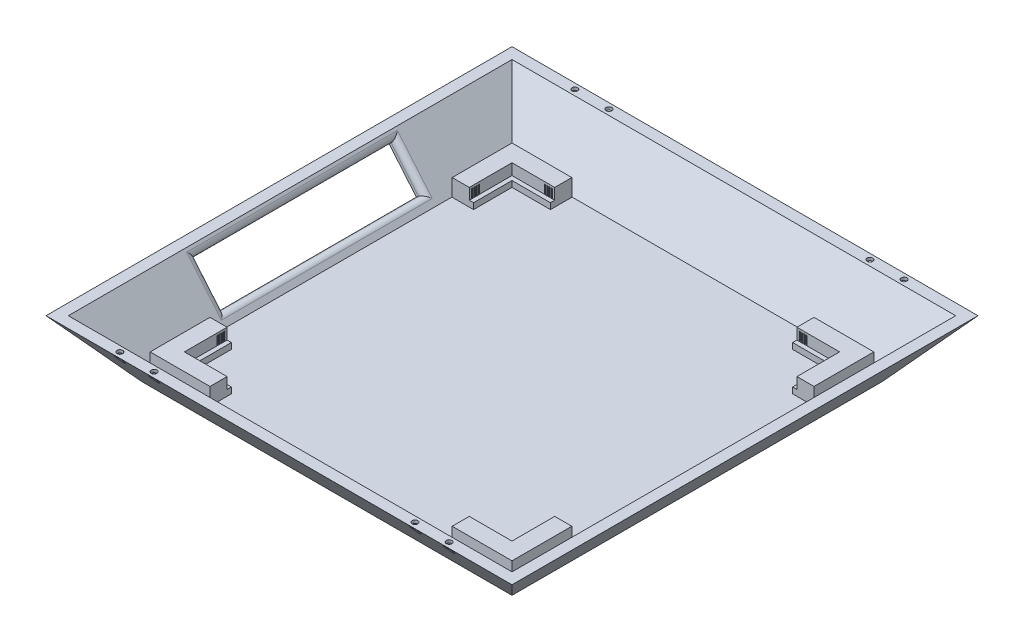
from build123d import *

# Parameters (mm, degrees)
SKETCH1_W            = 130
SKETCH1_H            = 130
BOSS_EXTRUDE1_DEPTH  = 20
BOSS_EXTRUDE1_DRAFT  = -40
SHELL1_T             = -3
BOSS_EXTRUDE2_DEPTH  = 6
BOSS_EXTRUDE3_DEPTH  = 2.1
SKETCH4_W            = 0.4
SKETCH4_H            = 3
BOSS_EXTRUDE4_DEPTH  = 0.2
CHAMFER2_SIZE        = 0.15
SKETCH5_W            = 0.4
SKETCH5_H            = 3
BOSS_EXTRUDE5_DEPTH  = 0.2
CHAMFER3_SIZE        = 0.15
SKETCH6_W            = 0.4
SKETCH6_H            = 3
BOSS_EXTRUDE6_DEPTH  = 0.2
CHAMFER4_SIZE        = 0.15
SKETCH7_W            = 0.4
SKETCH7_H            = 3
BOSS_EXTRUDE7_DEPTH  = 0.2
CHAMFER5_SIZE        = 0.15
SKETCH8_W            = 0.4
SKETCH8_H            = 3
BOSS_EXTRUDE8_DEPTH  = 0.2
CHAMFER6_SIZE        = 0.15
SKETCH9_W            = 0.4
SKETCH9_H            = 3
BOSS_EXTRUDE9_DEPTH  = 0.2
CHAMFER7_SIZE        = 0.15
SKETCH10_W           = 0.4
SKETCH10_H           = 3
BOSS_EXTRUDE10_DEPTH = 0.2
CHAMFER8_SIZE        = 0.15
SKETCH11_W           = 0.4
SKETCH11_H           = 3
BOSS_EXTRUDE11_DEPTH = 0.2
CHAMFER9_SIZE        = 0.15
SKETCH13_W           = 70
SKETCH13_H           = 15
CUT_EXTRUDE2_DEPTH   = 3.2
FILLET1_R            = 2
SKETCH22_R           = 1
CUT_EXTRUDE3_DEPTH   = 21.65
SKETCH22_5_R         = 1
CUT_EXTRUDE4_DEPTH   = 21.65
SKETCH22_6_R         = 1
CUT_EXTRUDE5_DEPTH   = 21.65
SKETCH22_7_R         = 1
CUT_EXTRUDE6_DEPTH   = 21.65
SKETCH22_8_R         = 1
CUT_EXTRUDE8_DEPTH   = 10
SKETCH22_9_R         = 1
CUT_EXTRUDE9_DEPTH   = 10
SKETCH22_10_R        = 1
CUT_EXTRUDE10_DEPTH  = 10
SKETCH22_11_R        = 1
CUT_EXTRUDE11_DEPTH  = 10
F_3DSKETCH3_R        = 1.5
CUT_EXTRUDE7_DEPTH   = 9
SKETCH23_R           = 1.5
CUT_EXTRUDE12_DEPTH  = 19


with BuildPart() as part:
    # Sketch1 → Boss-Extrude1 (with draft: the straight prism first)
    with BuildSketch(Plane(origin=(0, 0, 0), x_dir=(1, 0, 0), z_dir=(0, 1, 0))):
        Rectangle(SKETCH1_W, SKETCH1_H)
    extrude(amount=BOSS_EXTRUDE1_DEPTH)
    # Boss-Extrude1: the draft: its side faces are tilted about the plane it starts from
    boss_extrude1_sides = [part.faces().sort_by_distance(p)[0] for p in [
        (0, 10, 65),
        (65, 10, 0),
        (0, 10, -65),
        (-65, 10, 0),
    ]]
    draft(boss_extrude1_sides, Plane(origin=(0, 0, 0), x_dir=(1, 0, 0), z_dir=(0, 1, 0)), BOSS_EXTRUDE1_DRAFT)

    # Shell1
    shell1_openings = [part.faces().sort_by_distance(p)[0] for p in [
        (0, 20, 0),
    ]]
    offset(amount=SHELL1_T, openings=shell1_openings, kind=Kind.INTERSECTION)

    # Sketch2 → Boss-Extrude2 (add)
    with BuildSketch(Plane(origin=(0, 3, 0), x_dir=(1, 0, 0), z_dir=(0, 1, 0))):
        Polygon((-63.5, -63.5), (-42.5, -63.5), (-42.5, -57.5), (-57.5, -57.5), (-57.5, -42.5), (-63.5, -42.5), align=None)
        Polygon((57.5, -57.5), (42.5, -57.5), (42.5, -63.5), (63.5, -63.5), (63.5, -42.5), (57.5, -42.5), align=None)
        Polygon((-63.5, 42.5), (-57.5, 42.5), (-57.5, 57.5), (-42.5, 57.5), (-42.5, 63.5), (-63.5, 63.5), align=None)
        Polygon((57.5, 57.5), (57.5, 42.5), (63.5, 42.5), (63.5, 63.5), (42.5, 63.5), (42.5, 57.5), align=None)
    extrude(amount=BOSS_EXTRUDE2_DEPTH)

    # Sketch3 → Boss-Extrude3 (add)
    with BuildSketch(Plane(origin=(0, 3, 0), x_dir=(1, 0, 0), z_dir=(0, 1, 0))):
        Polygon((-57.5, -42.5), (-57.5, -57.5), (-42.5, -57.5), (-42.5, -56), (-56, -56), (-56, -42.5), align=None)
        Polygon((-57.5, 57.5), (-57.5, 42.5), (-56, 42.5), (-56, 56), (-42.5, 56), (-42.5, 57.5), align=None)
        Polygon((42.5, -56), (42.5, -57.5), (57.5, -57.5), (57.5, -42.5), (56, -42.5), (56, -56), align=None)
        Polygon((42.5, 57.5), (42.5, 56), (56, 56), (56, 42.5), (57.5, 42.5), (57.5, 57.5), align=None)
    extrude(amount=BOSS_EXTRUDE3_DEPTH)

    # Sketch4 → Boss-Extrude4 (add)
    with BuildSketch(Plane.XY.offset(-57.5)):
        with Locations((-43.5, 6.75)):
            Rectangle(SKETCH4_W, SKETCH4_H)
        with Locations((-44.3, 6.75)):
            Rectangle(SKETCH4_W, SKETCH4_H)
        with Locations((-45.1, 6.75)):
            Rectangle(SKETCH4_W, SKETCH4_H)
        with Locations((-45.9, 6.75)):
            Rectangle(SKETCH4_W, SKETCH4_H)
    extrude(amount=BOSS_EXTRUDE4_DEPTH)

    # Chamfer2
    chamfer2_edges = [part.edges().sort_by_distance(p)[0] for p in [
        (-43.3, 6.75, -57.3),
        (-43.7, 6.75, -57.3),
        (-44.1, 6.75, -57.3),
        (-44.5, 6.75, -57.3),
        (-44.9, 6.75, -57.3),
        (-45.3, 6.75, -57.3),
        (-45.7, 6.75, -57.3),
        (-46.1, 6.75, -57.3),
    ]]
    chamfer(chamfer2_edges, length=CHAMFER2_SIZE)

    # Sketch5 → Boss-Extrude5 (add)
    with BuildSketch(Plane(origin=(-57.5, 0, 0), x_dir=(0, 0, -1), z_dir=(1, 0, 0))):
        with Locations((43.5, 6.75)):
            Rectangle(SKETCH5_W, SKETCH5_H)
        with Locations((44.3, 6.75)):
            Rectangle(SKETCH5_W, SKETCH5_H)
        with Locations((45.1, 6.75)):
            Rectangle(SKETCH5_W, SKETCH5_H)
        with Locations((45.9, 6.75)):
            Rectangle(SKETCH5_W, SKETCH5_H)
    extrude(amount=BOSS_EXTRUDE5_DEPTH)

    # Chamfer3
    chamfer3_edges = [part.edges().sort_by_distance(p)[0] for p in [
        (-57.3, 6.75, -46.1),
        (-57.3, 6.75, -45.7),
        (-57.3, 6.75, -45.3),
        (-57.3, 6.75, -44.9),
        (-57.3, 6.75, -44.1),
        (-57.3, 6.75, -44.5),
        (-57.3, 6.75, -43.7),
        (-57.3, 6.75, -43.3),
    ]]
    chamfer(chamfer3_edges, length=CHAMFER3_SIZE)

    # Sketch6 → Boss-Extrude6 (add)
    with BuildSketch(Plane(origin=(-57.5, 0, 0), x_dir=(0, 0, -1), z_dir=(1, 0, 0))):
        with Locations((-43.5, 6.75)):
            Rectangle(SKETCH6_W, SKETCH6_H)
        with Locations((-44.3, 6.75)):
            Rectangle(SKETCH6_W, SKETCH6_H)
        with Locations((-45.1, 6.75)):
            Rectangle(SKETCH6_W, SKETCH6_H)
        with Locations((-45.9, 6.75)):
            Rectangle(SKETCH6_W, SKETCH6_H)
    extrude(amount=BOSS_EXTRUDE6_DEPTH)

    # Chamfer4
    chamfer4_edges = [part.edges().sort_by_distance(p)[0] for p in [
        (-57.3, 6.75, 44.5),
        (-57.3, 6.75, 44.1),
        (-57.3, 6.75, 43.3),
        (-57.3, 6.75, 43.7),
        (-57.3, 6.75, 44.9),
        (-57.3, 6.75, 45.3),
        (-57.3, 6.75, 45.7),
        (-57.3, 6.75, 46.1),
    ]]
    chamfer(chamfer4_edges, length=CHAMFER4_SIZE)

    # Sketch7 → Boss-Extrude7 (add)
    with BuildSketch(Plane(origin=(0, 0, 57.5), x_dir=(-1, 0, 0), z_dir=(0, 0, -1))):
        with Locations((43.5, 6.75)):
            Rectangle(SKETCH7_W, SKETCH7_H)
        with Locations((44.3, 6.75)):
            Rectangle(SKETCH7_W, SKETCH7_H)
        with Locations((45.1, 6.75)):
            Rectangle(SKETCH7_W, SKETCH7_H)
        with Locations((45.9, 6.75)):
            Rectangle(SKETCH7_W, SKETCH7_H)
    extrude(amount=BOSS_EXTRUDE7_DEPTH)

    # Chamfer5
    chamfer5_edges = [part.edges().sort_by_distance(p)[0] for p in [
        (-46.1, 6.75, 57.3),
        (-45.7, 6.75, 57.3),
        (-44.9, 6.75, 57.3),
        (-45.3, 6.75, 57.3),
        (-44.5, 6.75, 57.3),
        (-44.1, 6.75, 57.3),
        (-43.7, 6.75, 57.3),
        (-43.3, 6.75, 57.3),
    ]]
    chamfer(chamfer5_edges, length=CHAMFER5_SIZE)

    # Sketch8 → Boss-Extrude8 (add)
    with BuildSketch(Plane.ZY.offset(-57.5)):
        with Locations((43.5, 6.75)):
            Rectangle(SKETCH8_W, SKETCH8_H)
        with Locations((44.3, 6.75)):
            Rectangle(SKETCH8_W, SKETCH8_H)
        with Locations((45.1, 6.75)):
            Rectangle(SKETCH8_W, SKETCH8_H)
        with Locations((45.9, 6.75)):
            Rectangle(SKETCH8_W, SKETCH8_H)
    extrude(amount=BOSS_EXTRUDE8_DEPTH)

    # Chamfer6
    chamfer6_edges = [part.edges().sort_by_distance(p)[0] for p in [
        (57.3, 6.75, 46.1),
        (57.3, 6.75, 45.7),
        (57.3, 6.75, 45.3),
        (57.3, 6.75, 44.9),
        (57.3, 6.75, 44.5),
        (57.3, 6.75, 44.1),
        (57.3, 6.75, 43.7),
        (57.3, 6.75, 43.3),
    ]]
    chamfer(chamfer6_edges, length=CHAMFER6_SIZE)

    # Sketch9 → Boss-Extrude9 (add)
    with BuildSketch(Plane(origin=(0, 0, 57.5), x_dir=(-1, 0, 0), z_dir=(0, 0, -1))):
        with Locations((-43.45, 6.75)):
            Rectangle(SKETCH9_W, SKETCH9_H)
        with Locations((-44.25, 6.75)):
            Rectangle(SKETCH9_W, SKETCH9_H)
        with Locations((-45.05, 6.75)):
            Rectangle(SKETCH9_W, SKETCH9_H)
        with Locations((-45.85, 6.75)):
            Rectangle(SKETCH9_W, SKETCH9_H)
    extrude(amount=BOSS_EXTRUDE9_DEPTH)

    # Chamfer7
    chamfer7_edges = [part.edges().sort_by_distance(p)[0] for p in [
        (43.25, 6.75, 57.3),
        (43.65, 6.75, 57.3),
        (44.05, 6.75, 57.3),
        (44.45, 6.75, 57.3),
        (44.85, 6.75, 57.3),
        (45.25, 6.75, 57.3),
        (45.65, 6.75, 57.3),
        (46.05, 6.75, 57.3),
    ]]
    chamfer(chamfer7_edges, length=CHAMFER7_SIZE)

    # Sketch10 → Boss-Extrude10 (add)
    with BuildSketch(Plane.XY.offset(-57.5)):
        with Locations((43.5, 6.75)):
            Rectangle(SKETCH10_W, SKETCH10_H)
        with Locations((44.3, 6.75)):
            Rectangle(SKETCH10_W, SKETCH10_H)
        with Locations((45.1, 6.75)):
            Rectangle(SKETCH10_W, SKETCH10_H)
        with Locations((45.9, 6.75)):
            Rectangle(SKETCH10_W, SKETCH10_H)
    extrude(amount=BOSS_EXTRUDE10_DEPTH)

    # Chamfer8
    chamfer8_edges = [part.edges().sort_by_distance(p)[0] for p in [
        (46.1, 6.75, -57.3),
        (45.7, 6.75, -57.3),
        (45.3, 6.75, -57.3),
        (44.9, 6.75, -57.3),
        (44.5, 6.75, -57.3),
        (44.1, 6.75, -57.3),
        (43.7, 6.75, -57.3),
        (43.3, 6.75, -57.3),
    ]]
    chamfer(chamfer8_edges, length=CHAMFER8_SIZE)

    # Sketch11 → Boss-Extrude11 (add)
    with BuildSketch(Plane.ZY.offset(-57.5)):
        with Locations((-43.5, 6.75)):
            Rectangle(SKETCH11_W, SKETCH11_H)
        with Locations((-44.3, 6.75)):
            Rectangle(SKETCH11_W, SKETCH11_H)
        with Locations((-45.1, 6.75)):
            Rectangle(SKETCH11_W, SKETCH11_H)
        with Locations((-45.9, 6.75)):
            Rectangle(SKETCH11_W, SKETCH11_H)
    extrude(amount=BOSS_EXTRUDE11_DEPTH)

    # Chamfer9
    chamfer9_edges = [part.edges().sort_by_distance(p)[0] for p in [
        (57.3, 6.75, -43.3),
        (57.3, 6.75, -43.7),
        (57.3, 6.75, -44.1),
        (57.3, 6.75, -44.5),
        (57.3, 6.75, -44.9),
        (57.3, 6.75, -45.3),
        (57.3, 6.75, -45.7),
        (57.3, 6.75, -46.1),
    ]]
    chamfer(chamfer9_edges, length=CHAMFER9_SIZE)

    # Sketch13 → Cut-Extrude2 (cut)
    with BuildSketch(Plane(origin=(-38.143565774, -32.006251973, 0), x_dir=(0, 0, 1), z_dir=(-0.7660444431189777, -0.6427876096865398, 0))):
        with Locations((0, 54.834340416)):
            Rectangle(SKETCH13_W, SKETCH13_H)
    extrude(amount=-CUT_EXTRUDE2_DEPTH, mode=Mode.SUBTRACT)

    # Fillet1
    fillet1_edges = [part.edges().sort_by_distance(p)[0] for p in [
        (-71.09226705, 11.927652624, -35),
        (-66.271359977, 6.182319301, 0),
        (-75.913174122, 17.672985948, 0),
        (-71.09226705, 11.927652624, 35),
    ]]
    fillet(fillet1_edges, radius=FILLET1_R)

    # Sketch22 → Cut-Extrude3 (cut)
    with BuildSketch(Plane(origin=(0, 20, 0), x_dir=(1, 0, 0), z_dir=(0, 1, 0))):
        with Locations((-57.781992624, -79.825541038)):
            Circle(SKETCH22_R)
    extrude(amount=-CUT_EXTRUDE3_DEPTH, mode=Mode.SUBTRACT)

    # Sketch22_5 → Cut-Extrude4 (cut)
    with BuildSketch(Plane(origin=(0, 20, 0), x_dir=(1, 0, 0), z_dir=(0, 1, 0))):
        with Locations((-45.781992624, -79.825541038)):
            Circle(SKETCH22_5_R)
    extrude(amount=-CUT_EXTRUDE4_DEPTH, mode=Mode.SUBTRACT)

    # Sketch22_6 → Cut-Extrude5 (cut)
    with BuildSketch(Plane(origin=(0, 20, 0), x_dir=(1, 0, 0), z_dir=(0, 1, 0))):
        with Locations((-45.781992624, 79.821992624)):
            Circle(SKETCH22_6_R)
    extrude(amount=-CUT_EXTRUDE5_DEPTH, mode=Mode.SUBTRACT)

    # Sketch22_7 → Cut-Extrude6 (cut)
    with BuildSketch(Plane(origin=(0, 20, 0), x_dir=(1, 0, 0), z_dir=(0, 1, 0))):
        with Locations((-57.781992624, 79.821992624)):
            Circle(SKETCH22_7_R)
    extrude(amount=-CUT_EXTRUDE6_DEPTH, mode=Mode.SUBTRACT)

    # Sketch22_8 → Cut-Extrude8 (cut)
    with BuildSketch(Plane(origin=(0, 20, 0), x_dir=(1, 0, 0), z_dir=(0, 1, 0))):
        with Locations((45.781992624, -79.825541038)):
            Circle(SKETCH22_8_R)
    extrude(amount=-CUT_EXTRUDE8_DEPTH, mode=Mode.SUBTRACT)

    # Sketch22_9 → Cut-Extrude9 (cut)
    with BuildSketch(Plane(origin=(0, 20, 0), x_dir=(1, 0, 0), z_dir=(0, 1, 0))):
        with Locations((57.781992624, -79.825541038)):
            Circle(SKETCH22_9_R)
    extrude(amount=-CUT_EXTRUDE9_DEPTH, mode=Mode.SUBTRACT)

    # Sketch22_10 → Cut-Extrude10 (cut)
    with BuildSketch(Plane(origin=(0, 20, 0), x_dir=(1, 0, 0), z_dir=(0, 1, 0))):
        with Locations((57.781992624, 79.821992624)):
            Circle(SKETCH22_10_R)
    extrude(amount=-CUT_EXTRUDE10_DEPTH, mode=Mode.SUBTRACT)

    # Sketch22_11 → Cut-Extrude11 (cut)
    with BuildSketch(Plane(origin=(0, 20, 0), x_dir=(1, 0, 0), z_dir=(0, 1, 0))):
        with Locations((45.781992624, 79.821992624)):
            Circle(SKETCH22_11_R)
    extrude(amount=-CUT_EXTRUDE11_DEPTH, mode=Mode.SUBTRACT)

    # 3DSketch3 → Cut-Extrude7 (cut)
    with BuildSketch(Plane(origin=(-45.781970287, 10, -79.819541589), x_dir=(-0.07489564358828574, 0, 0.9971913771044636), z_dir=(0, -1, 0))):
        Circle(F_3DSKETCH3_R)
        with Locations((0.898335699, 11.960810665)):
            Circle(F_3DSKETCH3_R)
        with Locations((159.251148494, -11.960810665)):
            Circle(F_3DSKETCH3_R)
        with Locations((160.149484193, 0)):
            Circle(F_3DSKETCH3_R)
    extrude(amount=-CUT_EXTRUDE7_DEPTH, mode=Mode.SUBTRACT)

    # Sketch23 → Cut-Extrude12 (cut)
    with BuildSketch(Plane(origin=(0, 0, 0), x_dir=(1, 0, 0), z_dir=(0, 1, 0))):
        with Locations((57.781992624, 79.821992624)):
            Circle(SKETCH23_R)
        with Locations((45.781992624, 79.821992624)):
            Circle(SKETCH23_R)
        with Locations((45.781992624, -79.825541038)):
            Circle(SKETCH23_R)
        with Locations((57.781992624, -79.825541038)):
            Circle(SKETCH23_R)
    extrude(amount=CUT_EXTRUDE12_DEPTH, mode=Mode.SUBTRACT)


solid = part.part
